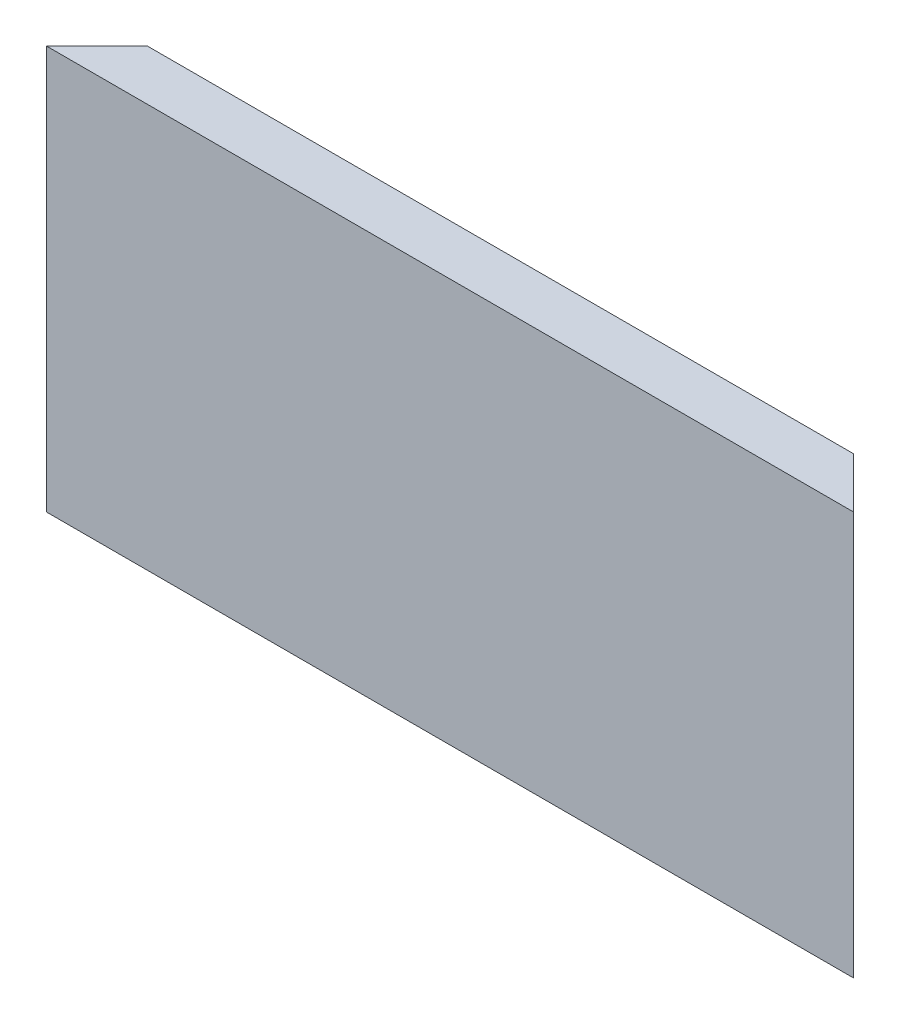
from build123d import *

# Parameters (mm, degrees)
BOSS_EXTRUDE1_DEPTH     = 80
CUT_EXTRUDE1_DEPTH      = 80
SKETCH3_W               = 3
SKETCH3_H               = 3
CUT_EXTRUDE2_DEPTH      = 81
CUT_EXTRUDE2_DEPTH_BACK = 1


with BuildPart() as part:
    # Sketch1 → Boss-Extrude1 (new body)
    with BuildSketch(Plane(origin=(0, 0, 0), x_dir=(0, 0, -1), z_dir=(1, 0, 0))):
        Polygon((-2.5, -20), (2.5, -15), (2.5, 20), (-2.5, 20), align=None)
    extrude(amount=BOSS_EXTRUDE1_DEPTH)

    # Sketch2 → Cut-Extrude1 (cut)
    with BuildSketch(Plane(origin=(0, 20, 0), x_dir=(1, 0, 0), z_dir=(0, 1, 0))):
        Polygon((80, 2.5), (75, 2.5), (80, -2.5), align=None)
        Polygon((0, -2.5), (5, 2.5), (0, 2.5), align=None)
    extrude(amount=-CUT_EXTRUDE1_DEPTH, mode=Mode.SUBTRACT)

    # Sketch3 → Cut-Extrude2 (cut, two sides)
    with BuildSketch(Plane(origin=(0, 0, 0), x_dir=(0, 0, -1), z_dir=(1, 0, 0))) as cut_extrude2_sk:
        with Locations((1, 15)):
            Rectangle(SKETCH3_W, SKETCH3_H)
    extrude(amount=CUT_EXTRUDE2_DEPTH, mode=Mode.SUBTRACT)
    extrude(cut_extrude2_sk.sketch, amount=-CUT_EXTRUDE2_DEPTH_BACK, mode=Mode.SUBTRACT)


solid = part.part
